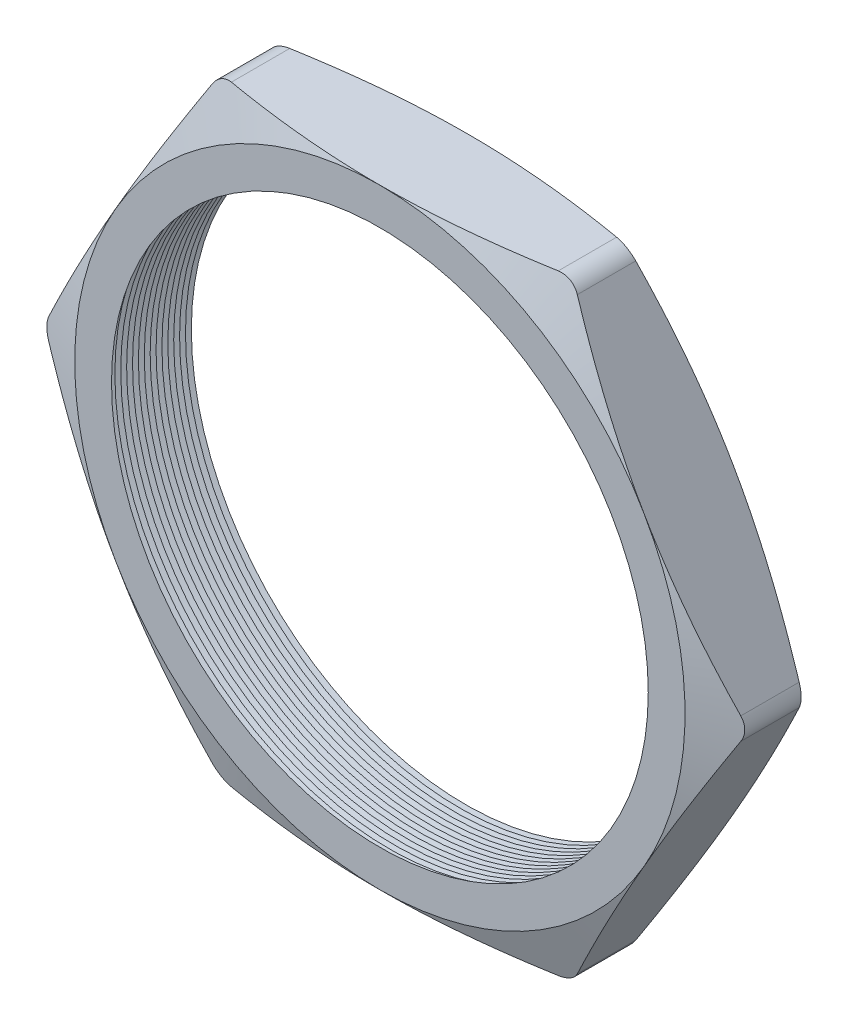
from build123d import *

# Parameters (mm, degrees)
SKETCH1_R          = 9.271
EXTRUDE1_DEPTH     = 3.048
FILLET1_R          = 0.762
SKETCH2_OUTSIDE_W  = 54.786
SKETCH2_OUTSIDE_H  = 51.76
SKETCH2_OUTSIDE_R  = 10.541
CUT_EXTRUDE1_DEPTH = 4.048
CUT_EXTRUDE1_DRAFT = -70
SKETCH3_OUTSIDE_W  = 54.786
SKETCH3_OUTSIDE_H  = 51.76
SKETCH3_OUTSIDE_R  = 10.541
CUT_EXTRUDE2_DEPTH = 4.0480001
CUT_EXTRUDE2_DRAFT = -70
LPATTERN1_COUNT    = 15
LPATTERN1_PITCH    = 0.2032


with BuildPart() as part:
    # Sketch1 → Extrude1 (new body)
    with BuildSketch(Plane.XY):
        Polygon((-12.171698375, 0), (-6.085849188, -10.541), (6.085849188, -10.541), (12.171698375, 0), (6.085849188, 10.541), (-6.085849188, 10.541), align=None)
        Circle(SKETCH1_R, mode=Mode.SUBTRACT)
    extrude(amount=EXTRUDE1_DEPTH)

    # Fillet1
    fillet1_edges = [part.edges().sort_by_distance(p)[0] for p in [
        (12.171698375, 0, 1.524),
        (6.085849188, -10.541, 1.524),
        (-6.085849188, -10.541, 1.524),
        (-12.171698375, 0, 1.524),
        (-6.085849188, 10.541, 1.524),
        (6.085849188, 10.541, 1.524),
    ]]
    fillet(fillet1_edges, radius=FILLET1_R)


with BuildPart() as cut_extrude1_tool:
    # Sketch2 outside → Cut-Extrude1 (with draft: the straight prism first)
    with BuildSketch(Plane.XY.offset(3.048)):
        Rectangle(SKETCH2_OUTSIDE_W, SKETCH2_OUTSIDE_H)
        Circle(SKETCH2_OUTSIDE_R, mode=Mode.SUBTRACT)
    extrude(amount=-CUT_EXTRUDE1_DEPTH)
    # Cut-Extrude1: the draft: its side faces are tilted about the plane it starts from
    cut_extrude1_sides = [cut_extrude1_tool.faces().sort_by_distance(p)[0] for p in [
        (0, -25.88, 1.024),
        (27.393, 0, 1.024),
        (0, 25.88, 1.024),
        (-27.393, 0, 1.024),
        (-10.541, 0, 1.024),
    ]]
    draft(cut_extrude1_sides, Plane.XY.offset(3.048), CUT_EXTRUDE1_DRAFT)


with BuildPart() as part_1:
    add(part.part)

    # Cut-Extrude1: cut by cut_extrude1_tool
    add(cut_extrude1_tool.part, mode=Mode.SUBTRACT)


with BuildPart() as cut_extrude2_tool:
    # Sketch3 outside → Cut-Extrude2 (with draft: the straight prism first)
    with BuildSketch(Plane(origin=(0, 0, 0), x_dir=(-1, 0, 0), z_dir=(0, 0, -1))):
        Rectangle(SKETCH3_OUTSIDE_W, SKETCH3_OUTSIDE_H)
        Circle(SKETCH3_OUTSIDE_R, mode=Mode.SUBTRACT)
    extrude(amount=-CUT_EXTRUDE2_DEPTH)
    # Cut-Extrude2: the draft: its side faces are tilted about the plane it starts from
    cut_extrude2_sides = [cut_extrude2_tool.faces().sort_by_distance(p)[0] for p in [
        (0, -25.88, 2.02400005),
        (-27.393, 0, 2.02400005),
        (0, 25.88, 2.02400005),
        (27.393, 0, 2.02400005),
        (10.541, 0, 2.02400005),
    ]]
    draft(cut_extrude2_sides, Plane(origin=(0, 0, 0), x_dir=(-1, 0, 0), z_dir=(0, 0, -1)), CUT_EXTRUDE2_DRAFT)


with BuildPart() as part_2:
    add(part_1.part)

    # Cut-Extrude2: cut by cut_extrude2_tool
    add(cut_extrude2_tool.part, mode=Mode.SUBTRACT)

    # Sketch4 → Cut-Revolve1 (revolve, cut)
    with BuildSketch(Plane(origin=(0, 0, 0), x_dir=(1, 0, 0), z_dir=(0, 1, 0))):
        Polygon((-9.271, -3.048), (-9.271, -2.608059095), (-9.652, -2.828029547), align=None)
    cut_revolve1 = revolve(axis=Axis((0, 0, 3.048), (0, 0, -1)), mode=Mode.SUBTRACT)

    # LPattern1: Cut-Revolve1 ×15
    with Locations(*[(0, 0, -i * LPATTERN1_PITCH) for i in range(1, LPATTERN1_COUNT)]):
        add(cut_revolve1, mode=Mode.SUBTRACT)


solid = part_2.part
